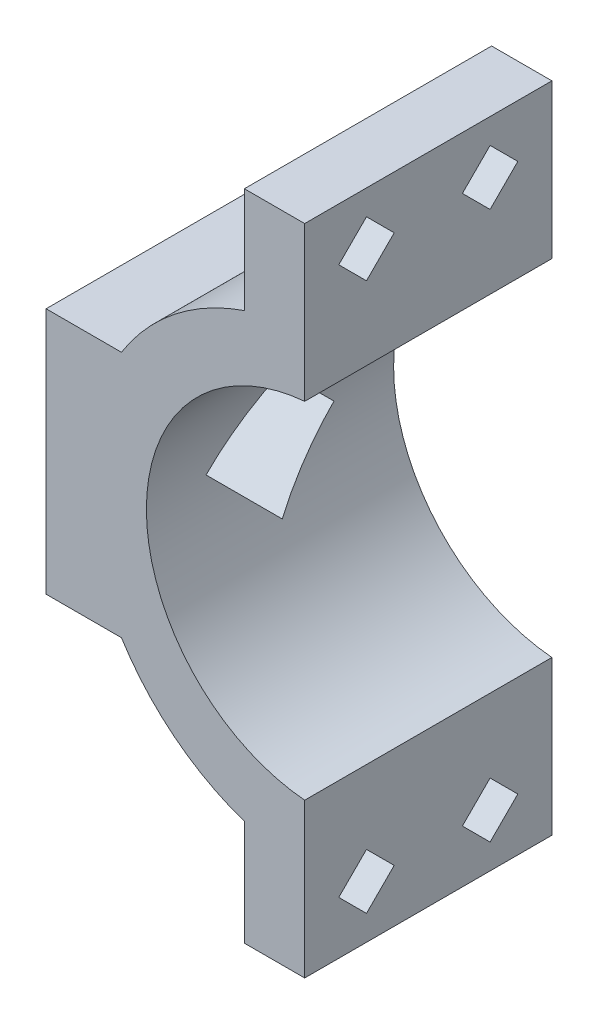
from build123d import *

# Parameters (mm, degrees)
BOSS_EXTRUDE1_DEPTH = 10.414
CUT_EXTRUDE1_DEPTH  = 6.08
CUT_EXTRUDE3_DEPTH  = 2.38125
CUT_EXTRUDE2_DEPTH  = 22.784724751


with BuildPart() as part:
    # Sketch1 → Boss-Extrude1 (new body, symmetric)
    with BuildSketch(Plane.XY):
        with BuildLine():
            Line((-1.27, 18.632678954), (-1.27, 14.549677831))
            ThreePointArc((-1.27, 14.549677831), (-10.766948848, 9.86807162), (-14.605, 0))
            Line((-14.605, 0), (-23.054724751, 0))
            Line((-23.054724751, 0), (-23.054724751, 10.414))
            Line((-23.054724751, 10.414), (-16.704724751, 10.414))
            ThreePointArc((-16.704724751, 10.414), (-12.237922792, 15.418575509), (-6.35, 18.632678954))
            Line((-6.35, 18.632678954), (-6.35, 27.522678954))
            Line((-6.35, 27.522678954), (-1.27, 27.522678954))
            Line((-1.27, 27.522678954), (-1.27, 18.632678954))
        make_face()
    boss_extrude1 = extrude(amount=BOSS_EXTRUDE1_DEPTH, both=True)

    # Mirror1: Boss-Extrude1 across plane
    add(boss_extrude1.mirror(Plane(origin=(-23.054724751, 0, 10.414), x_dir=(0, 0, 1), z_dir=(0, 1, 0))))

    # Sketch2 → Cut-Extrude1 (cut, through all)
    with BuildSketch(Plane.ZY.offset(6.35)):
        Polygon((5.207, 25.412545545), (2.872133409, 23.077678954), (5.207, 20.742812362), (7.541866591, 23.077678954), align=None)
        Polygon((-7.541866591, 23.077678954), (-5.207, 20.742812362), (-2.872133409, 23.077678954), (-5.207, 25.412545545), align=None)
    cut_extrude1 = extrude(amount=-CUT_EXTRUDE1_DEPTH, mode=Mode.SUBTRACT)

    # Sketch5 → Cut-Extrude3 (cut)
    with BuildSketch(Plane.ZY.offset(6.35)):
        Polygon((-8.873174209, 23.077678954), (-7.040087105, 19.902678954), (-3.373912895, 19.902678954), (-1.540825791, 23.077678954), (-3.373912895, 26.252678954), (-7.040087105, 26.252678954), align=None)
        Polygon((1.540825791, 23.077678954), (3.373912895, 19.902678954), (7.040087105, 19.902678954), (8.873174209, 23.077678954), (7.040087105, 26.252678954), (3.373912895, 26.252678954), align=None)
    cut_extrude3 = extrude(amount=-CUT_EXTRUDE3_DEPTH, mode=Mode.SUBTRACT)

    # Mirror2: Cut-Extrude1, Cut-Extrude3 across plane
    add(cut_extrude1.mirror(Plane.ZX), mode=Mode.SUBTRACT)
    add(cut_extrude3.mirror(Plane.ZX), mode=Mode.SUBTRACT)

    # Sketch3 → Cut-Extrude2 (cut, through all)
    with BuildSketch(Plane.ZY.offset(23.054724751)):
        Polygon((0, 5.388153673), (-5.388153673, 0), (0, -5.388153673), (5.388153673, 0), align=None)
    extrude(amount=-CUT_EXTRUDE2_DEPTH, mode=Mode.SUBTRACT)


solid = part.part
